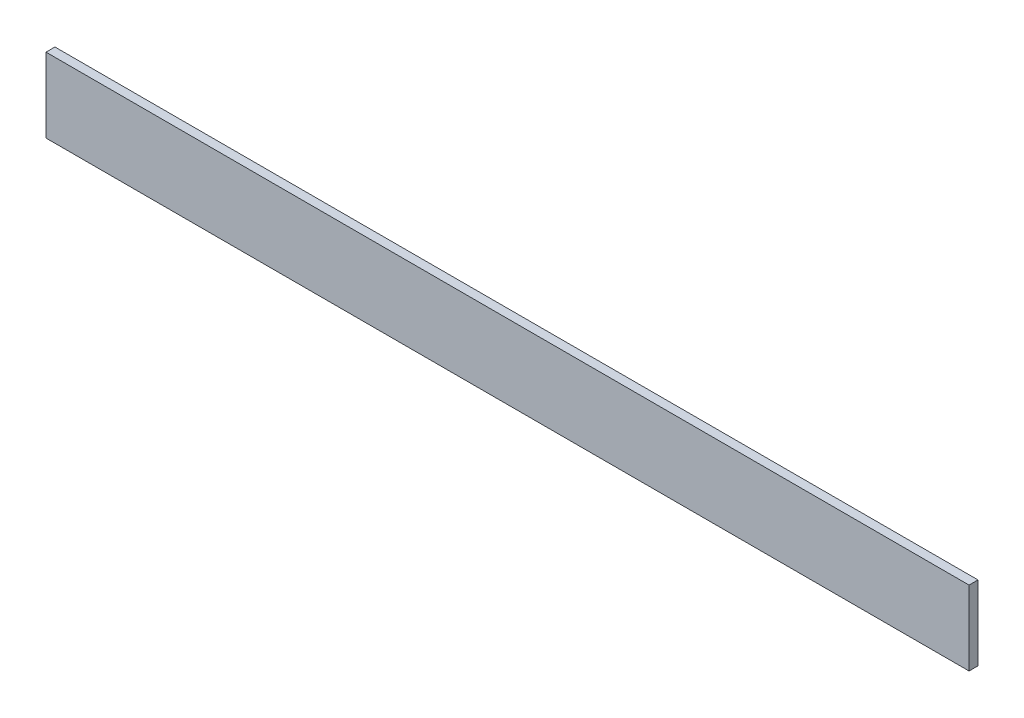
from build123d import *

# Parameters (mm, degrees)
EXTRUDE_1_DEPTH     = 310
SKETCH_2_W          = 22
SKETCH_2_H          = 22
CUT_EXTRUDE_1_DEPTH = 26


with BuildPart() as part:
    # Эскиз1 → Вытянуть-Тонкостенный1 (new body)
    with BuildSketch(Plane(origin=(0, 0, 0), x_dir=(0, 0, -1), z_dir=(1, 0, 0))):
        Polygon((0, 25), (0, 0), (25, 0), (25, 3), (3, 3), (3, 25), align=None)
    extrude(amount=EXTRUDE_1_DEPTH)

    # Эскиз2 → Вырез-Вытянуть1 (cut, through all)
    with BuildSketch(Plane.XZ):
        with Locations((299, -14)):
            Rectangle(SKETCH_2_W, SKETCH_2_H)
    extrude(amount=-CUT_EXTRUDE_1_DEPTH, mode=Mode.SUBTRACT)


solid = part.part
